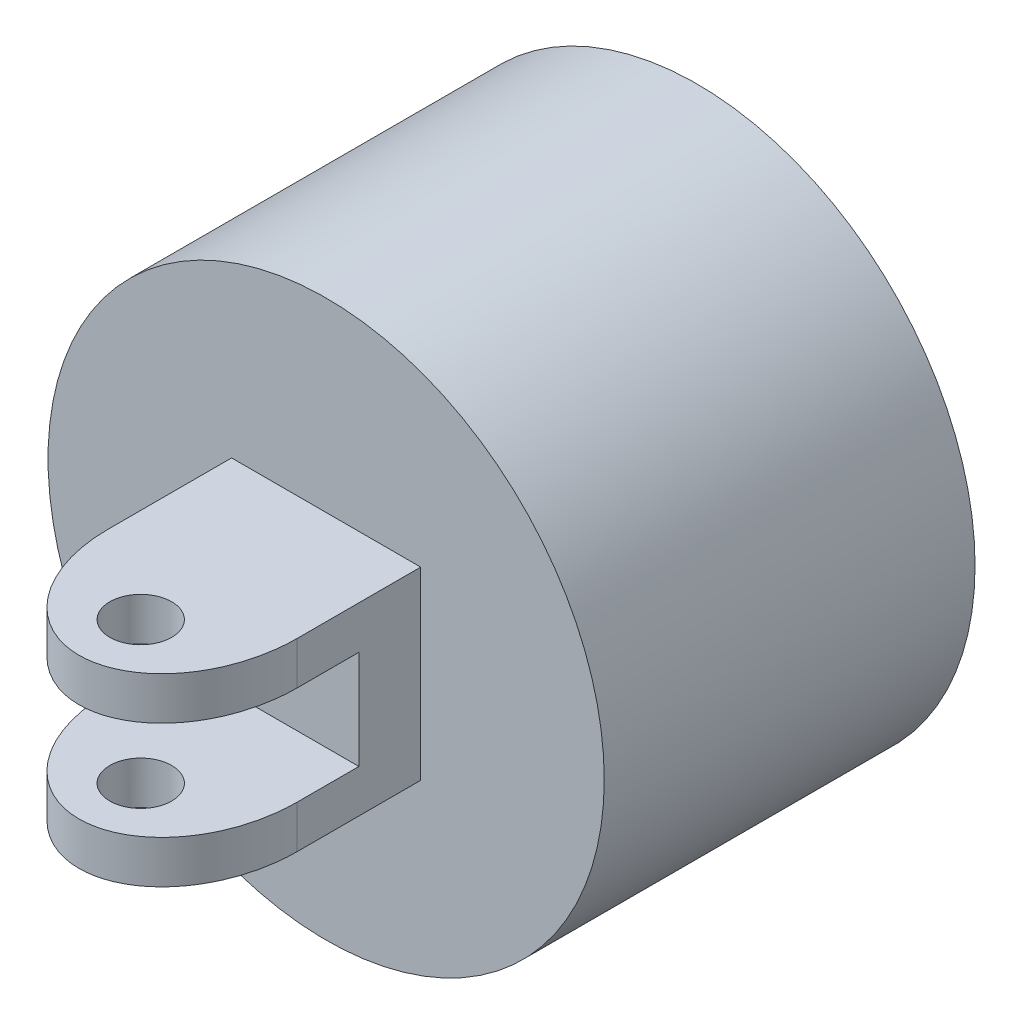
from build123d import *

# Parameters (mm, degrees)
SKETCH1_R           = 22.5
BOSS_EXTRUDE1_DEPTH = 30
SKETCH2_R           = 7.5
SKETCH2_W           = 3
SKETCH2_H           = 30
SKETCH2_W_2         = 30
SKETCH2_H_2         = 3
CUT_EXTRUDE1_DEPTH  = 10
SKETCH3_W           = 15.299534312
SKETCH3_H           = 14.93812799
BOSS_EXTRUDE2_DEPTH = 20
CUT_EXTRUDE2_DEPTH  = 20
SKETCH5_R           = 2.5
CUT_EXTRUDE4_DEPTH  = 20


with BuildPart() as part:
    # Sketch1 → Boss-Extrude1 (new body)
    with BuildSketch(Plane.XY):
        Circle(SKETCH1_R)
    extrude(amount=BOSS_EXTRUDE1_DEPTH)

    # Sketch2 → Cut-Extrude1 (cut)
    with BuildSketch(Plane(origin=(0, 0, 0), x_dir=(-1, 0, 0), z_dir=(0, 0, -1))):
        Circle(SKETCH2_R)
        Rectangle(SKETCH2_W, SKETCH2_H)
        Rectangle(SKETCH2_W_2, SKETCH2_H_2)
    extrude(amount=-CUT_EXTRUDE1_DEPTH, mode=Mode.SUBTRACT)

    # Sketch3 → Boss-Extrude2 (add)
    with BuildSketch(Plane.XY.offset(30)):
        Rectangle(SKETCH3_W, SKETCH3_H)
    extrude(amount=BOSS_EXTRUDE2_DEPTH)

    # Sketch4 → Cut-Extrude2 (cut)
    with BuildSketch(Plane.ZY.offset(7.649767156)):
        Polygon((40, 4), (50, 4), (50, 0), (50, -4), (40, -4), (35, -4), (35, 4), align=None)
    extrude(amount=-CUT_EXTRUDE2_DEPTH, mode=Mode.SUBTRACT)

    # Sketch5 → Cut-Extrude4 (cut)
    with BuildSketch(Plane(origin=(0, 7.469063995, 0), x_dir=(1, 0, 0), z_dir=(0, 1, 0))):
        with Locations((0, -45)):
            Circle(SKETCH5_R)
        with BuildLine():
            Line((7.649767156, -50), (7.649767156, -40))
            add(Edge.make_bspline(
                [(0, -50), (7.649767156, -50), (7.649767156, -40)],
                knots=[3.141592654, 3.141592654, 3.141592654, 4.71238898, 4.71238898, 4.71238898], degree=2, weights=[1, 0.707106781, 1]))
            Line((0, -50), (7.649767156, -50))
        make_face()
        with BuildLine():
            Line((-7.649767156, -50), (0, -50))
            add(Edge.make_bspline(
                [(-7.649767156, -40), (-7.649767156, -50), (0, -50)],
                knots=[1.570796327, 1.570796327, 1.570796327, 3.141592654, 3.141592654, 3.141592654], degree=2, weights=[1, 0.707106781, 1]))
            Line((-7.649767156, -40), (-7.649767156, -50))
        make_face()
    extrude(amount=-CUT_EXTRUDE4_DEPTH, mode=Mode.SUBTRACT)


solid = part.part
